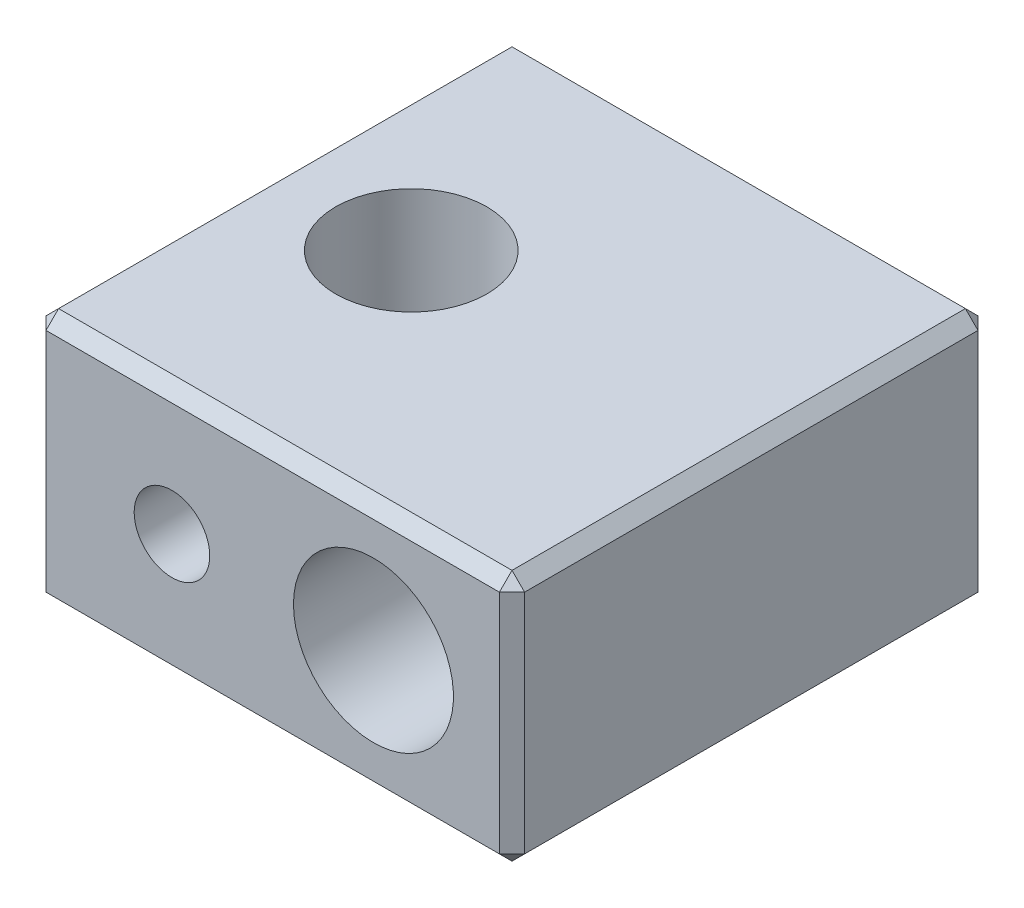
from build123d import *

# Parameters (mm, degrees)
SKETCH2_W           = 19
SKETCH2_H           = 19
SKETCH2_R           = 3
BOSS_EXTRUDE1_DEPTH = 10
SKETCH3_R           = 3.25
CUT_EXTRUDE1_DEPTH  = 1.5
SKETCH7_R           = 3.175
CUT_EXTRUDE5_DEPTH  = 20
CUT_EXTRUDE9_REACH  = 12
SKETCH12_R          = 1.5
SKETCH14_R          = 1.5
CUT_EXTRUDE11_DEPTH = 5
CHAMFER1_SIZE       = 0.5


with BuildPart() as part:
    # Sketch2 → Boss-Extrude1 (new body)
    with BuildSketch(Plane(origin=(0, 0, 0), x_dir=(1, 0, 0), z_dir=(0, 1, 0))):
        Rectangle(SKETCH2_W, SKETCH2_H)
        with Locations((-4, 0)):
            Circle(SKETCH2_R, mode=Mode.SUBTRACT)
    extrude(amount=BOSS_EXTRUDE1_DEPTH)

    # Sketch3 → Cut-Extrude1 (cut)
    with BuildSketch(Plane.XZ):
        with Locations((-4, 0)):
            Circle(SKETCH3_R)
    extrude(amount=-CUT_EXTRUDE1_DEPTH, mode=Mode.SUBTRACT)

    # Sketch7 → Cut-Extrude5 (cut, through all)
    with BuildSketch(Plane(origin=(0, 0, -9.5), x_dir=(-1, 0, 0), z_dir=(0, 0, -1))):
        with Locations((-4, 5)):
            Circle(SKETCH7_R)
    extrude(amount=-CUT_EXTRUDE5_DEPTH, mode=Mode.SUBTRACT)

    # Sketch12 → Cut-Extrude9 (cut, up to next)
    with BuildSketch(Plane(origin=(0, 0, 0), x_dir=(1, 0, 0), z_dir=(0, 1, 0)), mode=Mode.PRIVATE) as cut_extrude9_sk1:
        with Locations((4, 0)):
            Circle(SKETCH12_R)
    cut_extrude9_tool1 = extrude(cut_extrude9_sk1.sketch, amount=CUT_EXTRUDE9_REACH, mode=Mode.PRIVATE) & part.part
    add(cut_extrude9_tool1.solids().sort_by_distance((4, 0, 0))[0], mode=Mode.SUBTRACT)

    # Sketch14 → Cut-Extrude11 (cut)
    with BuildSketch(Plane(origin=(0, 0, 9.5), x_dir=(-1, 0, 0), z_dir=(0, 0, -1))):
        with Locations((4, 5)):
            Circle(SKETCH14_R)
    extrude(amount=CUT_EXTRUDE11_DEPTH, mode=Mode.SUBTRACT)

    # Chamfer1
    chamfer1_edges = [part.edges().sort_by_distance(p)[0] for p in [
        (-9.5, 10, 0),
        (0, 10, 9.5),
        (9.5, 10, 0),
        (0, 0, 9.5),
        (-9.5, 0, 0),
        (0, 0, -9.5),
        (9.5, 0, 0),
        (0, 10, -9.5),
        (9.5, 5, 9.5),
        (-9.5, 5, 9.5),
        (-9.5, 5, -9.5),
        (9.5, 5, -9.5),
    ]]
    chamfer(chamfer1_edges, length=CHAMFER1_SIZE)


solid = part.part
